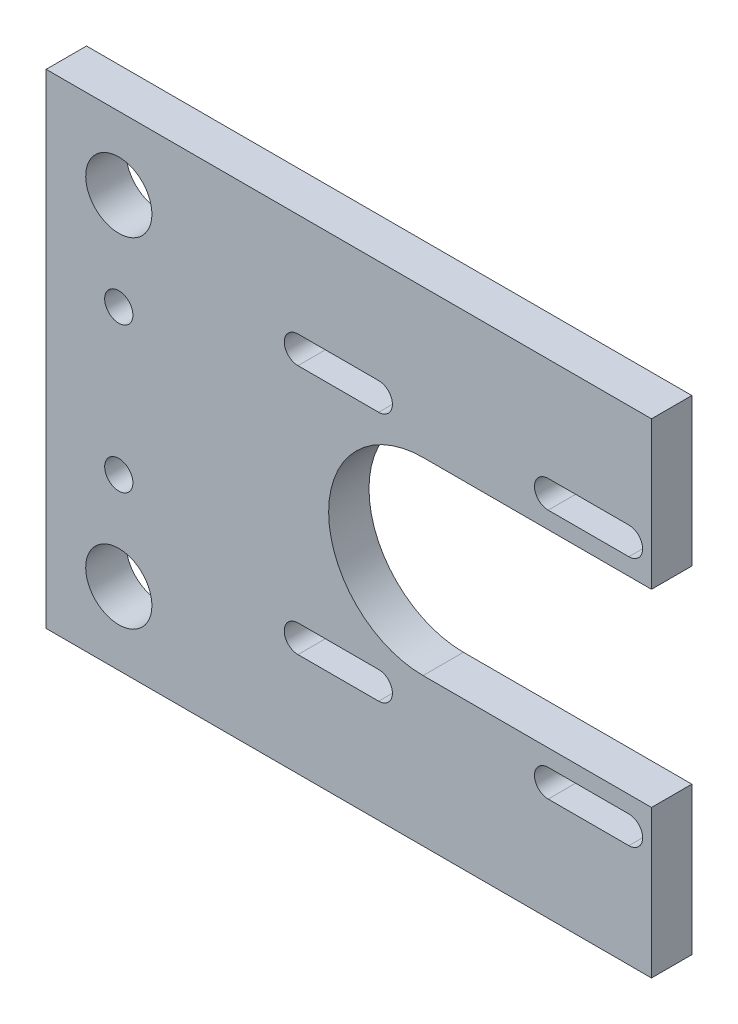
from build123d import *

# Parameters (mm, degrees)
SKETCH1_W           = 5
SKETCH1_H           = 60
BOSS_EXTRUDE1_DEPTH = 5
SKETCH2_W           = 5
SKETCH2_H           = 60
BOSS_EXTRUDE2_DEPTH = 50
CUT_EXTRUDE4_DEPTH  = 6
CUT_EXTRUDE5_DEPTH  = 6
SKETCH7_W           = 5
SKETCH7_H           = 60
BOSS_EXTRUDE3_DEPTH = 20
SKETCH8_R           = 4.1
SKETCH8_R_2         = 1.75
CUT_EXTRUDE6_DEPTH  = 6


with BuildPart() as part:
    # Sketch1 → Boss-Extrude1 (new body)
    with BuildSketch(Plane(origin=(0, 0, 0), x_dir=(0, 0, -1), z_dir=(1, 0, 0))):
        with Locations((-36.107304337, -1.744616853)):
            Rectangle(SKETCH1_W, SKETCH1_H)
    extrude(amount=BOSS_EXTRUDE1_DEPTH)

    # Sketch2 → Boss-Extrude2 (add)
    with BuildSketch(Plane(origin=(5, 0, 0), x_dir=(0, 0, -1), z_dir=(1, 0, 0))):
        with Locations((-36.107304337, -1.744616853)):
            Rectangle(SKETCH2_W, SKETCH2_H)
    extrude(amount=BOSS_EXTRUDE2_DEPTH)

    # Sketch5 → Cut-Extrude4 (cut, through all)
    with BuildSketch(Plane(origin=(0, 0, 33.607304337), x_dir=(-1, 0, 0), z_dir=(0, 0, -1))):
        with BuildLine():
            Line((-26.7, -13.444616853), (-56.7, -13.444616853))
            ThreePointArc((-56.7, -13.444616853), (-68.4, -1.744616853), (-56.7, 9.955383147))
            Line((-56.7, 9.955383147), (-26.7, 9.955383147))
            ThreePointArc((-26.7, 9.955383147), (-15, -1.744616853), (-26.7, -13.444616853))
        make_face()
    extrude(amount=-CUT_EXTRUDE4_DEPTH, mode=Mode.SUBTRACT)

    # Sketch6 → Cut-Extrude5 (cut, through all)
    with BuildSketch(Plane(origin=(0, 0, 33.607304337), x_dir=(-1, 0, 0), z_dir=(0, 0, -1))):
        with BuildLine():
            Line((-42.2, 12.055383147), (-52.2, 12.055383147))
            ThreePointArc((-52.2, 12.055383147), (-53.9, 13.755383147), (-52.2, 15.455383147))
            Line((-52.2, 15.455383147), (-42.2, 15.455383147))
            ThreePointArc((-42.2, 15.455383147), (-40.5, 13.755383147), (-42.2, 12.055383147))
        make_face()
        with BuildLine():
            Line((-42.2, -18.944616853), (-52.2, -18.944616853))
            ThreePointArc((-52.2, -18.944616853), (-53.9, -17.244616853), (-52.2, -15.544616853))
            Line((-52.2, -15.544616853), (-42.2, -15.544616853))
            ThreePointArc((-42.2, -15.544616853), (-40.5, -17.244616853), (-42.2, -18.944616853))
        make_face()
        with BuildLine():
            Line((-11.2, -18.944616853), (-21.2, -18.944616853))
            ThreePointArc((-21.2, -18.944616853), (-22.9, -17.244616853), (-21.2, -15.544616853))
            Line((-21.2, -15.544616853), (-11.2, -15.544616853))
            ThreePointArc((-11.2, -15.544616853), (-9.5, -17.244616853), (-11.2, -18.944616853))
        make_face()
        with BuildLine():
            Line((-11.2, 12.055383147), (-21.2, 12.055383147))
            ThreePointArc((-21.2, 12.055383147), (-22.9, 13.755383147), (-21.2, 15.455383147))
            Line((-21.2, 15.455383147), (-11.2, 15.455383147))
            ThreePointArc((-11.2, 15.455383147), (-9.5, 13.755383147), (-11.2, 12.055383147))
        make_face()
    extrude(amount=-CUT_EXTRUDE5_DEPTH, mode=Mode.SUBTRACT)

    # Sketch7 → Boss-Extrude3 (add)
    with BuildSketch(Plane.ZY):
        with Locations((36.107304337, -1.744616853)):
            Rectangle(SKETCH7_W, SKETCH7_H)
    extrude(amount=BOSS_EXTRUDE3_DEPTH)

    # Sketch8 → Cut-Extrude6 (cut, through all)
    with BuildSketch(Plane(origin=(0, 0, 33.607304337), x_dir=(-1, 0, 0), z_dir=(0, 0, -1))):
        with Locations((11, 19.255383147)):
            Circle(SKETCH8_R)
        with Locations((11, -22.744616853)):
            Circle(SKETCH8_R)
        with Locations((11, -10.744616853)):
            Circle(SKETCH8_R_2)
        with Locations((11, 7.255383147)):
            Circle(SKETCH8_R_2)
    extrude(amount=-CUT_EXTRUDE6_DEPTH, mode=Mode.SUBTRACT)


solid = part.part
